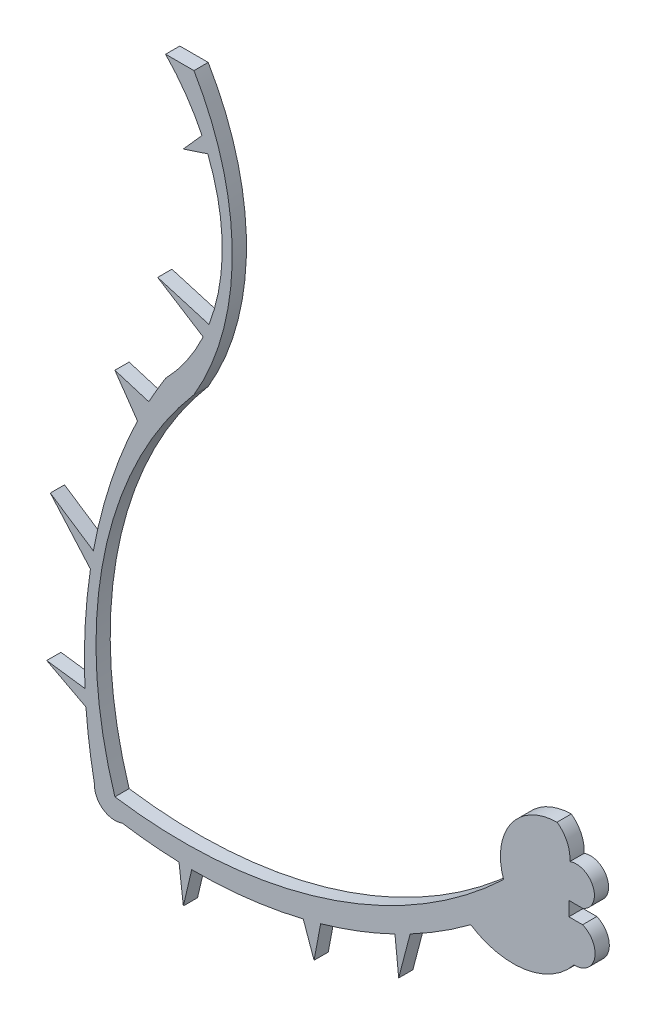
from build123d import *

# Parameters (mm, degrees)
BOSS_EXTRUDE1_DEPTH = 1.524


with BuildPart() as part:
    # Sketch1 → Boss-Extrude1 (new body)
    with BuildSketch(Plane.XY):
        with BuildLine():
            Line((-6.707532294, -1.524), (-8.180261599, -1.524))
            Line((-8.180261599, -1.524), (-8.180261599, 0))
            Line((-8.180261599, 0), (-6.707532294, 0))
            ThreePointArc((-6.707532294, 0), (-5.566232372, 2.510291461), (-8.076523834, 3.651591383))
            ThreePointArc((-8.076523834, 3.651591383), (-8.369654544, 5.318155721), (-9.445515373, 6.624251346))
            ThreePointArc((-9.445515373, 6.624251346), (-14.401020029, 3.989835798), (-15.174514112, -1.568840176))
            ThreePointArc((-15.174514112, -1.568840176), (-34.4819371, -12.946344269), (-56.822290696, -14.716311235))
            ThreePointArc((-56.822290696, -14.716311235), (-57.967480091, 7.157863233), (-48.348408829, 26.836898663))
            ThreePointArc((-48.348408829, 26.836898663), (-44.246968405, 41.873579483), (-48.348408829, 56.910260303))
            Line((-48.348408829, 56.910260303), (-51.389474112, 56.910260303))
            ThreePointArc((-51.389474112, 56.910260303), (-49.216811045, 54.268914149), (-47.487026065, 51.318487362))
            Line((-47.487026065, 51.318487362), (-49.488434682, 49.065882941))
            Line((-49.488434682, 49.065882941), (-46.871051317, 49.924357948))
            ThreePointArc((-46.871051317, 49.924357948), (-45.319923788, 42.05338237), (-46.740158296, 34.157738817))
            Line((-46.740158296, 34.157738817), (-52.238150108, 35.775293633))
            Line((-52.238150108, 35.775293633), (-47.363457894, 32.688041845))
            ThreePointArc((-47.363457894, 32.688041845), (-49.134990292, 29.596317231), (-51.389474112, 26.836898663))
            ThreePointArc((-51.389474112, 26.836898663), (-52.30892636, 25.313565237), (-53.180617863, 23.762407254))
            Line((-53.180617863, 23.762407254), (-56.822290696, 24.868655134))
            Line((-56.822290696, 24.868655134), (-54.401149248, 21.377722623))
            ThreePointArc((-54.401149248, 21.377722623), (-57.245514929, 14.322290898), (-59.129790068, 6.952145706))
            Line((-59.129790068, 6.952145706), (-63.741523441, 10.016836401))
            Line((-63.741523441, 10.016836401), (-59.441762763, 5.107182625))
            ThreePointArc((-59.441762763, 5.107182625), (-60.018868287, -0.566291047), (-60.028931863, -6.26903188))
            Line((-60.028931863, -6.26903188), (-64.127892645, -5.71704549))
            Line((-64.127892645, -5.71704549), (-59.924854983, -7.930246527))
            ThreePointArc((-59.924854983, -7.930246527), (-59.56576898, -11.286860212), (-59.00955991, -14.616489269))
            ThreePointArc((-59.00955991, -14.616489269), (-58.101840622, -16.493067556), (-56.034305753, -16.759150133))
            ThreePointArc((-56.034305753, -16.759150133), (-53.001957218, -17.139391155), (-49.951949985, -17.332203884))
            Line((-49.951949985, -17.332203884), (-49.488434682, -21.174519893))
            Line((-49.488434682, -21.174519893), (-48.591597193, -17.35752957))
            ThreePointArc((-48.591597193, -17.35752957), (-42.573321797, -17.020849086), (-36.640297554, -15.956792779))
            Line((-36.640297554, -15.956792779), (-35.482848207, -19.212777207))
            Line((-35.482848207, -19.212777207), (-34.776442064, -15.465610409))
            ThreePointArc((-34.776442064, -15.465610409), (-30.729531902, -14.124143433), (-26.812740931, -12.440170747))
            Line((-26.812740931, -12.440170747), (-26.416692929, -16.322506345))
            Line((-26.416692929, -16.322506345), (-25.185933177, -11.619136315))
            ThreePointArc((-25.185933177, -11.619136315), (-21.861410327, -9.695823756), (-18.695636823, -7.521091244))
            ThreePointArc((-18.695636823, -7.521091244), (-12.816455315, -8.747608772), (-7.631399226, -5.71704549))
            ThreePointArc((-7.631399226, -5.71704549), (-5.42183259, -4.005584271), (-6.707532294, -1.524))
        make_face()
    extrude(amount=BOSS_EXTRUDE1_DEPTH)


solid = part.part
